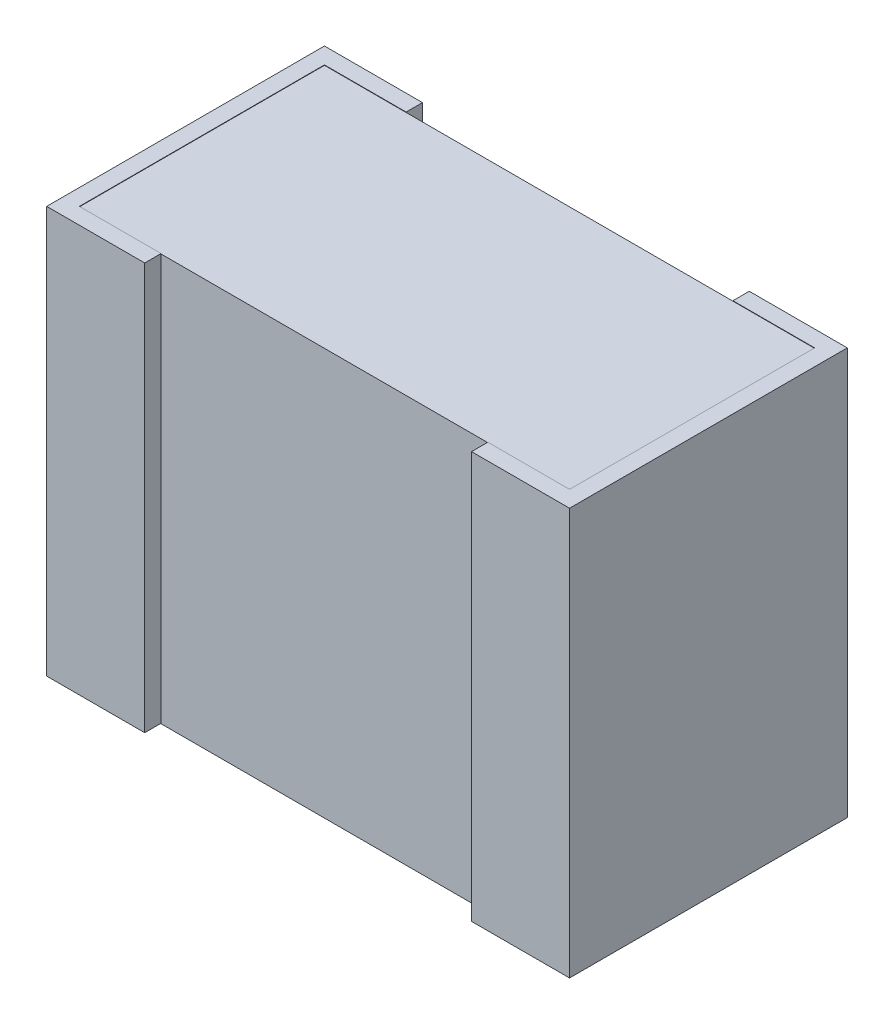
from build123d import *

# Parameters (mm, degrees)
SKETCH2_W           = 3
SKETCH2_H           = 1.5
BASE_EXTRUDE_DEPTH  = 1.245
BOSS_EXTRUDE8_DEPTH = 2.49


with BuildPart() as part:
    # Sketch2 → Base-Extrude (new body, symmetric)
    with BuildSketch(Plane(origin=(0, 0, 0), x_dir=(1, 0, 0), z_dir=(0, 1, 0))):
        Rectangle(SKETCH2_W, SKETCH2_H)
    extrude(amount=BASE_EXTRUDE_DEPTH, both=True)

    # Sketch3 → Boss-Extrude8 (add)
    with BuildSketch(Plane(origin=(0, 1.24754, 0), x_dir=(-1, 0, 0), z_dir=(0, 1, 0))):
        Polygon((1, 0.85), (1, 0.75), (1.5, 0.75), (1.5, -0.75), (1, -0.75), (1, -0.85), (1.6, -0.85), (1.6, 0.85), align=None)
    boss_extrude8 = extrude(amount=-BOSS_EXTRUDE8_DEPTH)

    # Espelhar1: Boss-Extrude8 across plane
    add(boss_extrude8.mirror(Plane(origin=(0, 0, 0), x_dir=(0, 0, 1), z_dir=(1, 0, 0))))


solid = part.part
